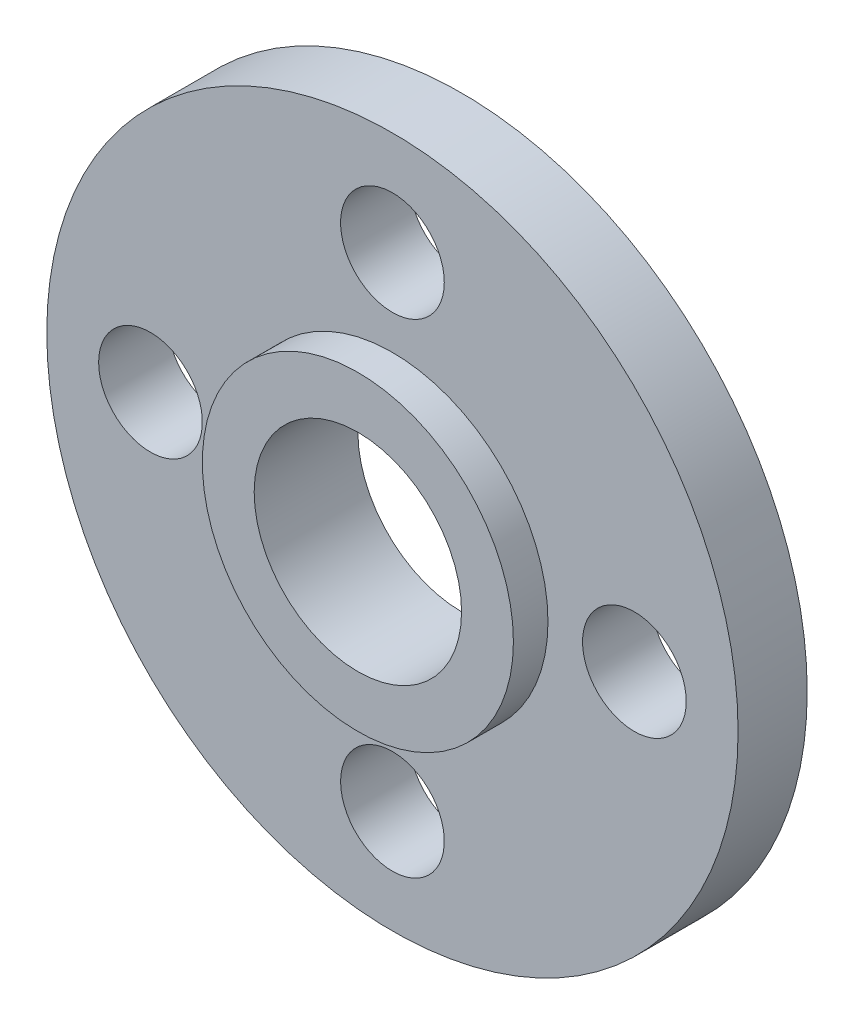
from build123d import *

# Parameters (mm, degrees)
SKETCH_1_R          = 10
EXTRUDE_1_DEPTH     = 2
SKETCH_2_R          = 1.5
CUT_EXTRUDE_1_DEPTH = 2
SKETCH_3_R          = 3
CUT_EXTRUDE_2_DEPTH = 2
SKETCH_4_R          = 4.5
SKETCH_4_R_2        = 3
EXTRUDE_4_DEPTH     = 1


with BuildPart() as part:
    # 草图1 → 凸台-拉伸1 (new body)
    with BuildSketch(Plane.XY):
        Circle(SKETCH_1_R)
    extrude(amount=EXTRUDE_1_DEPTH)

    # 草图2 → 切除-拉伸1 (cut)
    with BuildSketch(Plane.XY.offset(2)):
        with Locations((0, 7)):
            Circle(SKETCH_2_R)
        with Locations((7, 0)):
            Circle(SKETCH_2_R)
        with Locations((0, -7)):
            Circle(SKETCH_2_R)
        with Locations((-7, 0)):
            Circle(SKETCH_2_R)
    extrude(amount=-CUT_EXTRUDE_1_DEPTH, mode=Mode.SUBTRACT)

    # 草图3 → 切除-拉伸2 (cut)
    with BuildSketch(Plane.XY.offset(2)):
        Circle(SKETCH_3_R)
    extrude(amount=-CUT_EXTRUDE_2_DEPTH, mode=Mode.SUBTRACT)

    # 草图4 → 凸台-拉伸4 (add)
    with BuildSketch(Plane.XY.offset(2)):
        Circle(SKETCH_4_R)
        Circle(SKETCH_4_R_2, mode=Mode.SUBTRACT)
    extrude(amount=EXTRUDE_4_DEPTH)


solid = part.part
